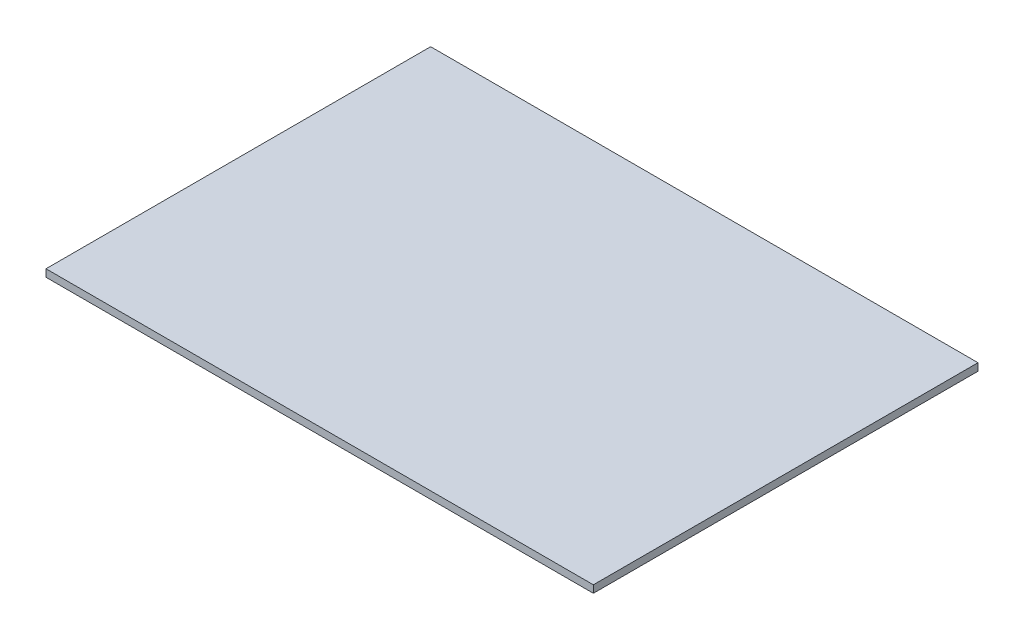
from build123d import *

# Parameters (mm, degrees)
SKETCH1_W           = 370
SKETCH1_H           = 260
BOSS_EXTRUDE1_DEPTH = 5


with BuildPart() as part:
    # Sketch1 → Boss-Extrude1 (new body)
    with BuildSketch(Plane(origin=(0, 0, 0), x_dir=(1, 0, 0), z_dir=(0, 1, 0))):
        Rectangle(SKETCH1_W, SKETCH1_H)
    extrude(amount=BOSS_EXTRUDE1_DEPTH)


solid = part.part
